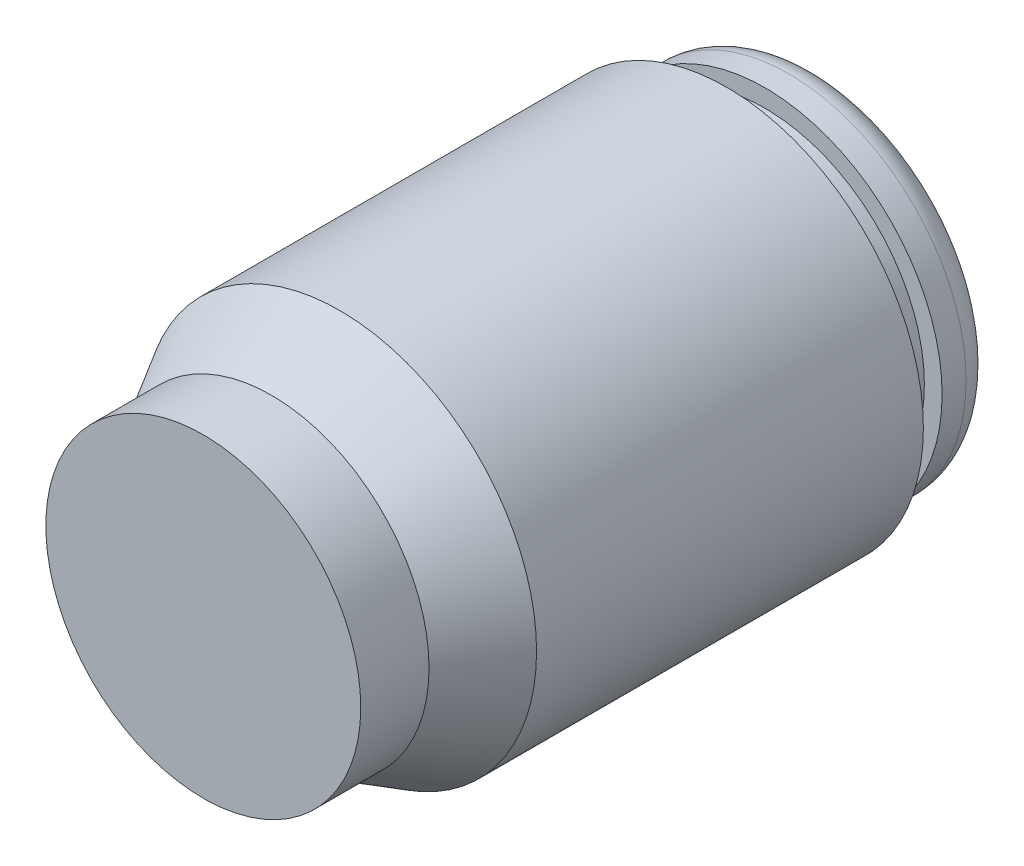
from build123d import *


with BuildPart() as part:
    # Sketch1 → Revolve1 (revolve)
    with BuildSketch(Plane(origin=(0, 0, 0), x_dir=(0, 0, -1), z_dir=(1, 0, 0))):
        with BuildLine():
            Line((14.859, 4.6863), (15.494, 4.6863))
            ThreePointArc((15.494, 4.6863), (16.032815367, 4.463115367), (16.256, 3.9243))
            Line((16.256, 3.9243), (16.256, 3.556))
            Line((16.256, 3.556), (15.875, 3.175))
            Line((15.875, 3.175), (3.609979933, 3.175))
            Line((3.609979933, 3.175), (3.609979933, 0))
            Line((3.609979933, 0), (0, 0))
            Line((0, 0), (0, 4.1656))
            Line((0, 4.1656), (1.806222222, 4.1656))
            Line((1.806222222, 4.1656), (3.609979933, 5.207))
            Line((3.609979933, 5.207), (13.843, 5.207))
            Line((13.843, 5.207), (13.843, 4.21767))
            Line((13.843, 4.21767), (14.859, 4.21767))
            Line((14.859, 4.21767), (14.859, 4.6863))
        make_face()
    revolve(axis=Axis((0, 0, 0), (0, 0, -1)))


solid = part.part
